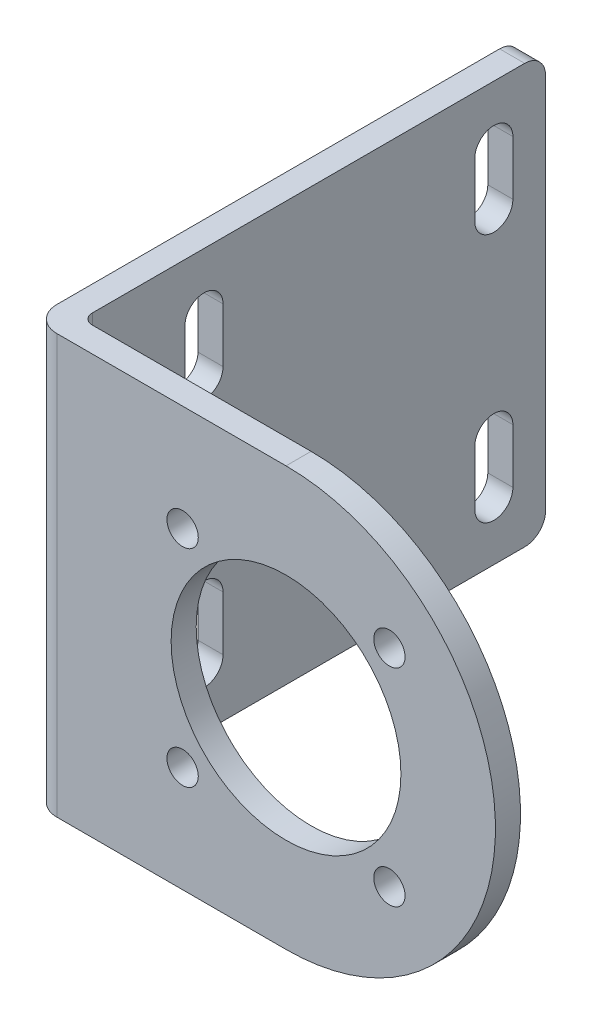
from build123d import *

# Parameters (mm, degrees)
SKETCH1_R           = 1.5
BOSS_EXTRUDE1_DEPTH = 2.4
SKETCH2_W           = 2.4
SKETCH2_H           = 40.1
BOSS_EXTRUDE2_DEPTH = 44.4
FILLET2_R           = 1
FILLET3_R           = 2.4
FILLET4_R           = 2
CUT_EXTRUDE1_DEPTH  = 45.4
SKETCH4_R           = 4
CUT_EXTRUDE2_DEPTH  = 2.4
SKETCH5_R           = 11
CUT_EXTRUDE3_DEPTH  = 2.4


with BuildPart() as part:
    # Sketch1 → Boss-Extrude1 (new body)
    with BuildSketch(Plane.XY):
        with BuildLine():
            Line((0, -20.05), (-24.35, -20.05))
            Line((-24.35, -20.05), (-24.35, 20.05))
            Line((-24.35, 20.05), (0, 20.05))
            ThreePointArc((0, 20.05), (20.05, 0), (0, -20.05))
        make_face()
        with Locations((-9.899494937, -9.899494937)):
            Circle(SKETCH1_R, mode=Mode.SUBTRACT)
        with Locations((-9.899494937, 9.899494937)):
            Circle(SKETCH1_R, mode=Mode.SUBTRACT)
        with Locations((9.899494937, 9.899494937)):
            Circle(SKETCH1_R, mode=Mode.SUBTRACT)
        with Locations((9.899494937, -9.899494937)):
            Circle(SKETCH1_R, mode=Mode.SUBTRACT)
    extrude(amount=BOSS_EXTRUDE1_DEPTH)

    # Sketch2 → Boss-Extrude2 (add)
    with BuildSketch(Plane(origin=(0, 0, 0), x_dir=(-1, 0, 0), z_dir=(0, 0, -1))):
        with Locations((23.15, 0)):
            Rectangle(SKETCH2_W, SKETCH2_H)
    extrude(amount=BOSS_EXTRUDE2_DEPTH)

    # Fillet2
    fillet2_edges = [part.edges().sort_by_distance(p)[0] for p in [
        (-21.95, 0, 0),
    ]]
    fillet(fillet2_edges, radius=FILLET2_R)

    # Fillet3
    fillet3_edges = [part.edges().sort_by_distance(p)[0] for p in [
        (-24.35, 0, 2.4),
    ]]
    fillet(fillet3_edges, radius=FILLET3_R)

    # Fillet4
    fillet4_edges = [part.edges().sort_by_distance(p)[0] for p in [
        (-23.15, 20.05, -44.4),
        (-23.15, -20.05, -44.4),
    ]]
    fillet(fillet4_edges, radius=FILLET4_R)

    # Sketch3 → Cut-Extrude1 (cut, through all)
    with BuildSketch(Plane.ZY.offset(24.35)):
        with BuildLine():
            Line((-41.27, 9.345), (-41.27, 14.545))
            ThreePointArc((-41.27, 14.545), (-39.445, 16.37), (-37.62, 14.545))
            Line((-37.62, 14.545), (-37.62, 9.345))
            ThreePointArc((-37.62, 9.345), (-39.445, 7.52), (-41.27, 9.345))
        make_face()
        with BuildLine():
            Line((-13.52, 9.345), (-13.52, 14.545))
            ThreePointArc((-13.52, 14.545), (-11.695, 16.37), (-9.87, 14.545))
            Line((-9.87, 14.545), (-9.87, 9.345))
            ThreePointArc((-9.87, 9.345), (-11.695, 7.52), (-13.52, 9.345))
        make_face()
        with BuildLine():
            Line((-41.27, -9.345), (-41.27, -14.545))
            ThreePointArc((-41.27, -14.545), (-39.445, -16.37), (-37.62, -14.545))
            Line((-37.62, -14.545), (-37.62, -9.345))
            ThreePointArc((-37.62, -9.345), (-39.445, -7.52), (-41.27, -9.345))
        make_face()
        with BuildLine():
            Line((-13.52, -9.345), (-13.52, -14.545))
            ThreePointArc((-13.52, -14.545), (-11.695, -16.37), (-9.87, -14.545))
            Line((-9.87, -14.545), (-9.87, -9.345))
            ThreePointArc((-9.87, -9.345), (-11.695, -7.52), (-13.52, -9.345))
        make_face()
    extrude(amount=-CUT_EXTRUDE1_DEPTH, mode=Mode.SUBTRACT)

    # Sketch4 → Cut-Extrude2 (cut)
    with BuildSketch(Plane.XY.offset(2.4)):
        Circle(SKETCH4_R)
    extrude(amount=-CUT_EXTRUDE2_DEPTH, mode=Mode.SUBTRACT)

    # Sketch5 → Cut-Extrude3 (cut)
    with BuildSketch(Plane.XY.offset(2.4)):
        Circle(SKETCH5_R)
    extrude(amount=-CUT_EXTRUDE3_DEPTH, mode=Mode.SUBTRACT)


solid = part.part
